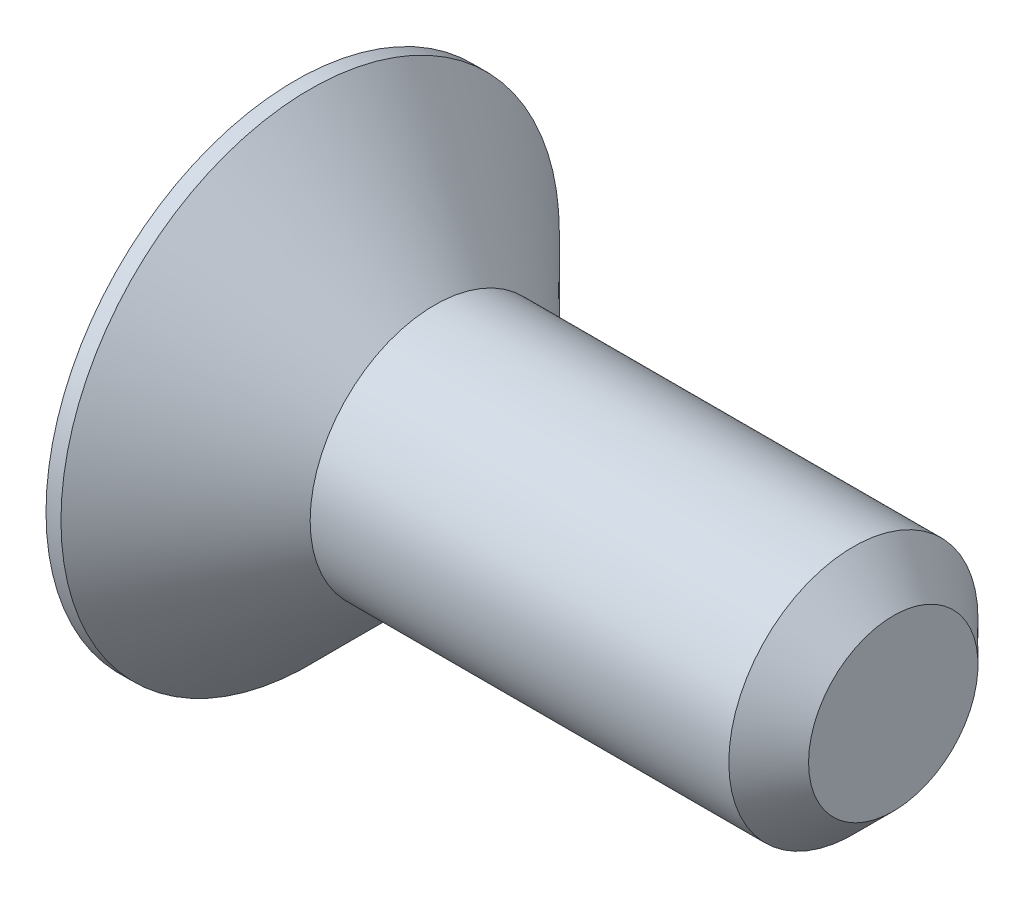
from build123d import *

# Parameters (mm, degrees)
CUT_EXTRUDE1_DEPTH = 1.9


with BuildPart() as part:
    # Sketch1 → Revolve1 (revolve)
    with BuildSketch(Plane.XY):
        Polygon((0, -2.5), (8.4, -2.5), (9.2, -1.7), (9.2, 0), (-2.8, 0), (-2.8, -5), (-2.5, -5), align=None)
    revolve(axis=Axis((-2.8, 0, 0), (1, 0, 0)))

    # Sketch2 → Cut-Extrude1 (cut)
    with BuildSketch(Plane.ZY.offset(2.8)):
        Polygon((0, 1.732050808), (-1.5, 0.866025404), (-1.5, -0.866025404), (0, -1.732050808), (1.5, -0.866025404), (1.5, 0.866025404), align=None)
    extrude(amount=-CUT_EXTRUDE1_DEPTH, mode=Mode.SUBTRACT)


solid = part.part
